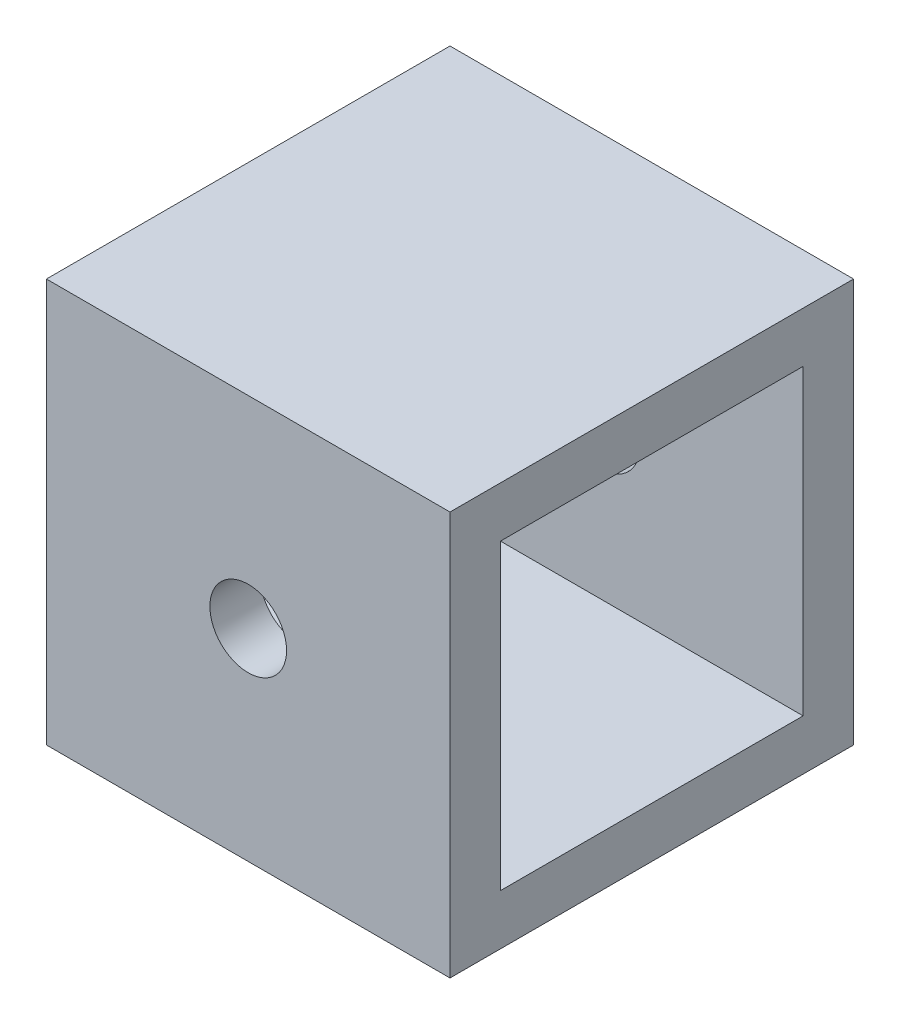
from build123d import *

# Parameters (mm, degrees)
SKETCH1_W           = 25.4
SKETCH1_H           = 25.4
SKETCH1_W_2         = 19.05
SKETCH1_H_2         = 19.05
EXTRUDE_THIN1_DEPTH = 25.4
SKETCH2_R           = 2.413
CUT_EXTRUDE1_DEPTH  = 26.4


with BuildPart() as part:
    # Sketch1 → Extrude-Thin1 (new body)
    with BuildSketch(Plane(origin=(0, 0, 0), x_dir=(0, 0, -1), z_dir=(1, 0, 0))):
        with Locations((12.7, 12.7)):
            Rectangle(SKETCH1_W, SKETCH1_H)
        with Locations((12.7, 12.7)):
            Rectangle(SKETCH1_W_2, SKETCH1_H_2, mode=Mode.SUBTRACT)
    extrude(amount=EXTRUDE_THIN1_DEPTH)

    # Sketch2 → Cut-Extrude1 (cut, through all)
    with BuildSketch(Plane.XY):
        with Locations((12.7, 12.7)):
            Circle(SKETCH2_R)
    extrude(amount=-CUT_EXTRUDE1_DEPTH, mode=Mode.SUBTRACT)


solid = part.part
